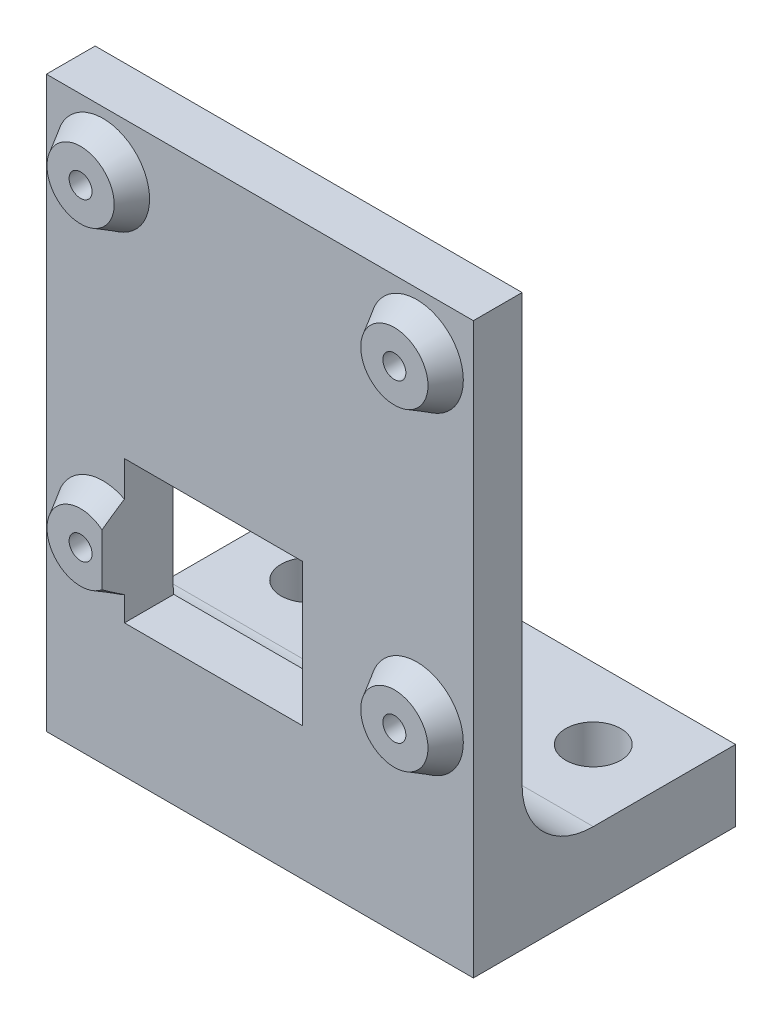
from build123d import *

# Parameters (mm, degrees)
BOSS_EXTRUDE1_DEPTH          = 19.05
M2_5X0_45_TAPPED_HOLE1_D     = 2.05
SKETCH6_OUTSIDE_W            = 56.088
SKETCH6_OUTSIDE_H            = 68.788
SKETCH6_OUTSIDE_R            = 3
CUT_EXTRUDE1_DEPTH           = 2
CUT_EXTRUDE1_TAPER           = 30
SKETCH7_W                    = 15.875
SKETCH7_H                    = 12.7
CUT_EXTRUDE2_DEPTH           = 3.0000001
CUT_EXTRUDE2_DEPTH_BACK      = 24.4
F_10_0_1935_DIAMETER_HOLE1_D = 4.9149


with BuildPart() as part:
    # Sketch1 → Boss-Extrude1 (new body, symmetric)
    with BuildSketch(Plane(origin=(0, 0, 0), x_dir=(0, 0, -1), z_dir=(1, 0, 0))):
        with BuildLine():
            Line((25.4, 0), (0, 0))
            Line((0, 0), (0, 50.8))
            Line((0, 50.8), (6.35, 50.8))
            Line((6.35, 50.8), (6.35, 12.7))
            ThreePointArc((6.35, 12.7), (8.209871939, 8.209871939), (12.7, 6.35))
            Line((12.7, 6.35), (25.4, 6.35))
            Line((25.4, 6.35), (25.4, 0))
        make_face()
    extrude(amount=BOSS_EXTRUDE1_DEPTH, both=True)

    # M2.5x0.45 Tapped Hole1 (through all)
    with Locations(Plane.XY):
        with Locations((-14, 45.75), (14, 45.75), (14, 17.75), (-14, 17.75)):
            Hole(M2_5X0_45_TAPPED_HOLE1_D / 2)

    # Sketch6 outside → Cut-Extrude1 (cut)
    with BuildSketch(Plane.XY):
        with Locations((0, 25.4)):
            Rectangle(SKETCH6_OUTSIDE_W, SKETCH6_OUTSIDE_H)
        with Locations((-14, 45.75)):
            Circle(SKETCH6_OUTSIDE_R, mode=Mode.SUBTRACT)
        with Locations((14, 45.75)):
            Circle(SKETCH6_OUTSIDE_R, mode=Mode.SUBTRACT)
        with Locations((14, 17.75)):
            Circle(SKETCH6_OUTSIDE_R, mode=Mode.SUBTRACT)
        with Locations((-14, 17.75)):
            Circle(SKETCH6_OUTSIDE_R, mode=Mode.SUBTRACT)
    extrude(amount=-CUT_EXTRUDE1_DEPTH, taper=CUT_EXTRUDE1_TAPER, mode=Mode.SUBTRACT)

    # Sketch7 → Cut-Extrude2 (cut, two sides)
    with BuildSketch(Plane.XY.offset(-2)) as cut_extrude2_sk:
        with Locations((-4.15, 18.225)):
            Rectangle(SKETCH7_W, SKETCH7_H)
    extrude(amount=CUT_EXTRUDE2_DEPTH, mode=Mode.SUBTRACT)
    extrude(cut_extrude2_sk.sketch, amount=-CUT_EXTRUDE2_DEPTH_BACK, mode=Mode.SUBTRACT)

    # #10 (0.1935) Diameter Hole1 (through all)
    with Locations(Plane(origin=(0, 6.35, 0), x_dir=(1, 0, 0), z_dir=(0, 1, 0))):
        with Locations((-12.7, 19.05), (0, 19.05), (12.7, 19.05)):
            Hole(F_10_0_1935_DIAMETER_HOLE1_D / 2)


solid = part.part
